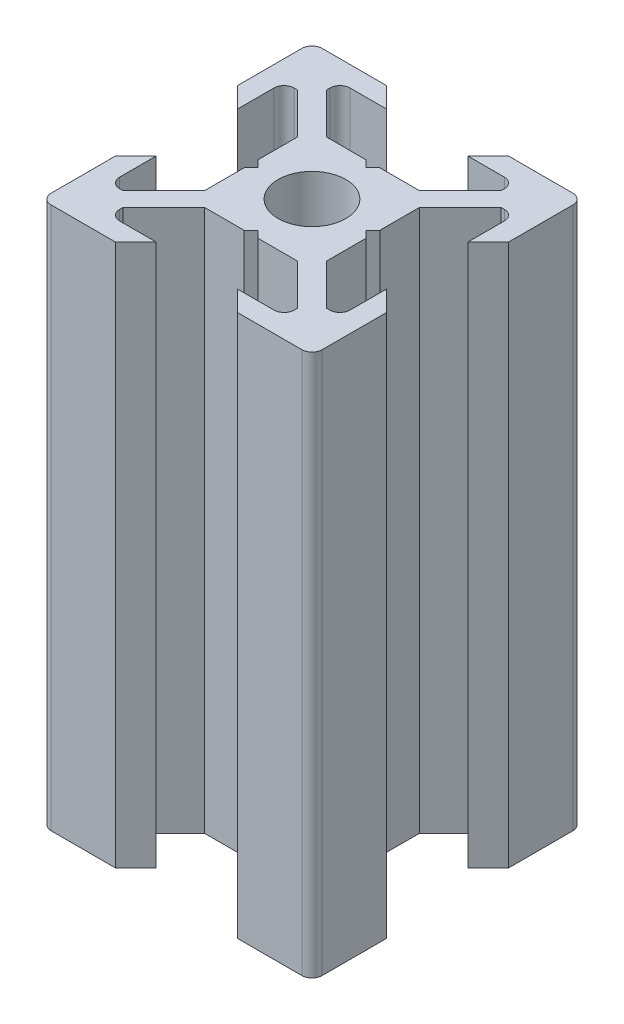
from build123d import *

# Parameters (mm, degrees)
ESQUISSE1_R      = 2.5
EXTRUSION1_DEPTH = 40
CONG_1_R         = 0.75


with BuildPart() as part:
    # Esquisse1 → Extrusion1 (new body)
    with BuildSketch(Plane(origin=(0, 0, 0), x_dir=(1, 0, 0), z_dir=(0, 1, 0))):
        Polygon((0, 4), (-0.5, 4.5), (-3.439339828, 4.5), (-6.439339828, 7.5), (-6.439339828, 8.5), (-3, 8.5), (-4.5, 10), (-10, 10), (-10, 4.5), (-8.5, 3), (-8.5, 6.439339828), (-7.5, 6.439339828), (-4.5, 3.439339828), (-4.5, 0.5), (-4, 0), (-4.5, -0.5), (-4.5, -3.439339828), (-7.5, -6.439339828), (-8.5, -6.439339828), (-8.5, -3), (-10, -4.5), (-10, -10), (-4.5, -10), (-3, -8.5), (-6.439339828, -8.5), (-6.439339828, -7.5), (-3.439339828, -4.5), (-0.5, -4.5), (0, -4), (0.5, -4.5), (3.439339828, -4.5), (6.439339828, -7.5), (6.439339828, -8.5), (3, -8.5), (4.5, -10), (10, -10), (10, -4.5), (8.5, -3), (8.5, -6.439339828), (7.5, -6.439339828), (4.5, -3.439339828), (4.5, -0.5), (4, 0), (4.5, 0.5), (4.5, 3.439339828), (7.5, 6.439339828), (8.5, 6.439339828), (8.5, 3), (10, 4.5), (10, 10), (4.5, 10), (3, 8.5), (6.439339828, 8.5), (6.439339828, 7.5), (3.439339828, 4.5), (0.5, 4.5), align=None)
        Circle(ESQUISSE1_R, mode=Mode.SUBTRACT)
    extrude(amount=EXTRUSION1_DEPTH)

    # Congé1
    cong_1_edges = [part.edges().sort_by_distance(p)[0] for p in [
        (6.439339828, 20, -8.5),
        (10, 20, -10),
        (8.5, 20, -6.439339828),
        (8.5, 20, 6.439339828),
        (10, 20, 10),
        (6.439339828, 20, 8.5),
        (-6.439339828, 20, 8.5),
        (-10, 20, 10),
        (-8.5, 20, 6.439339828),
        (-8.5, 20, -6.439339828),
        (-10, 20, -10),
        (-6.439339828, 20, -8.5),
    ]]
    fillet(cong_1_edges, radius=CONG_1_R)


solid = part.part
